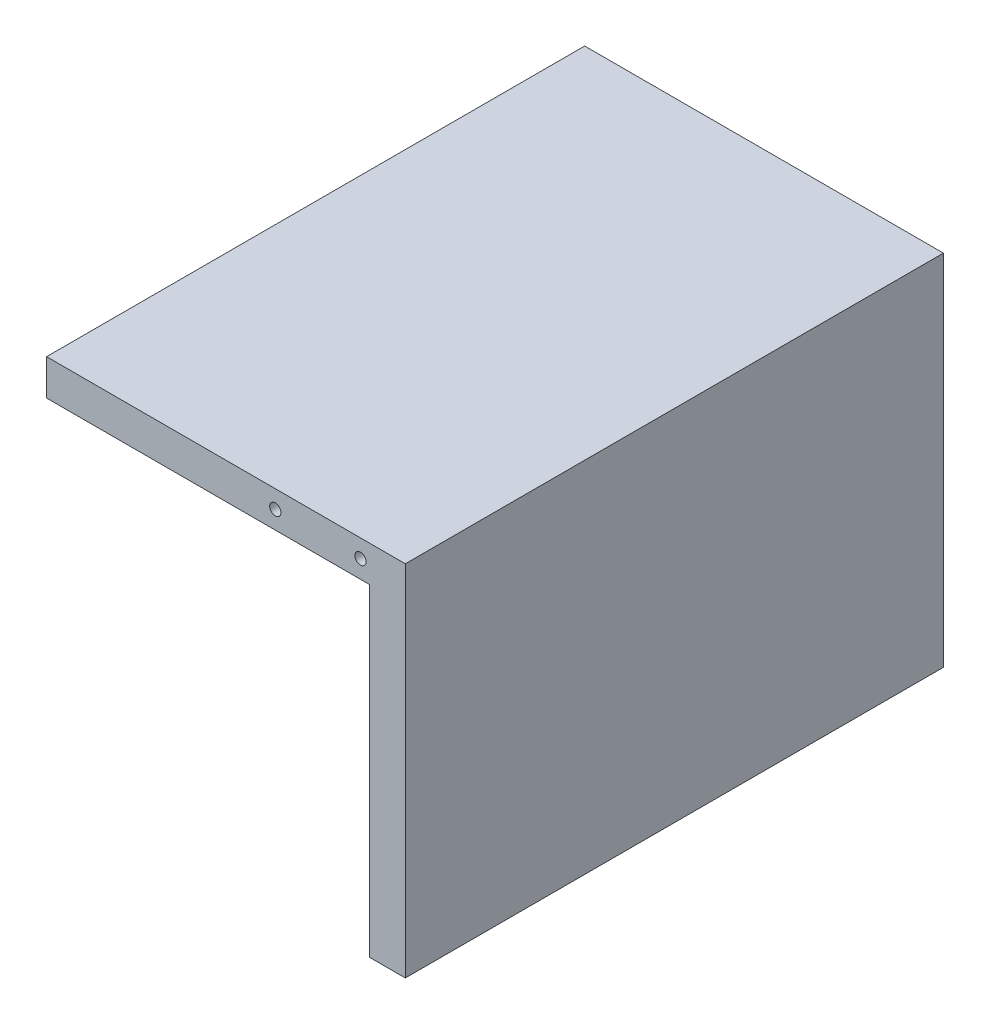
from build123d import *

# Parameters (mm, degrees)
ESTRUSIONE_ESTRUSIONE1_DEPTH = 120
FORO_FILETTATO_M3_1_D        = 2.5
FORO_FILETTATO_M3_1_DEPTH    = 10
FORO_FILETTATO_M3_1_TIP      = 0.751075774


with BuildPart() as part:
    # Schizzo1 → Estrusione-Estrusione1 (new body)
    with BuildSketch(Plane.XY):
        Polygon((0, 0), (-80, 0), (-80, -8), (-8, -8), (-8, -80), (0, -80), align=None)
    extrude(amount=ESTRUSIONE_ESTRUSIONE1_DEPTH)

    # Foro filettato M3-1
    with Locations(Plane.XY.offset(120)):
        with Locations((-10, -4), (-29, -4)):
            Hole(FORO_FILETTATO_M3_1_D / 2, depth=FORO_FILETTATO_M3_1_DEPTH)
            with Locations((0, 0, -(FORO_FILETTATO_M3_1_DEPTH + FORO_FILETTATO_M3_1_TIP / 2))):  # 118° drill point
                Cone(0, FORO_FILETTATO_M3_1_D / 2, FORO_FILETTATO_M3_1_TIP, mode=Mode.SUBTRACT)


solid = part.part
